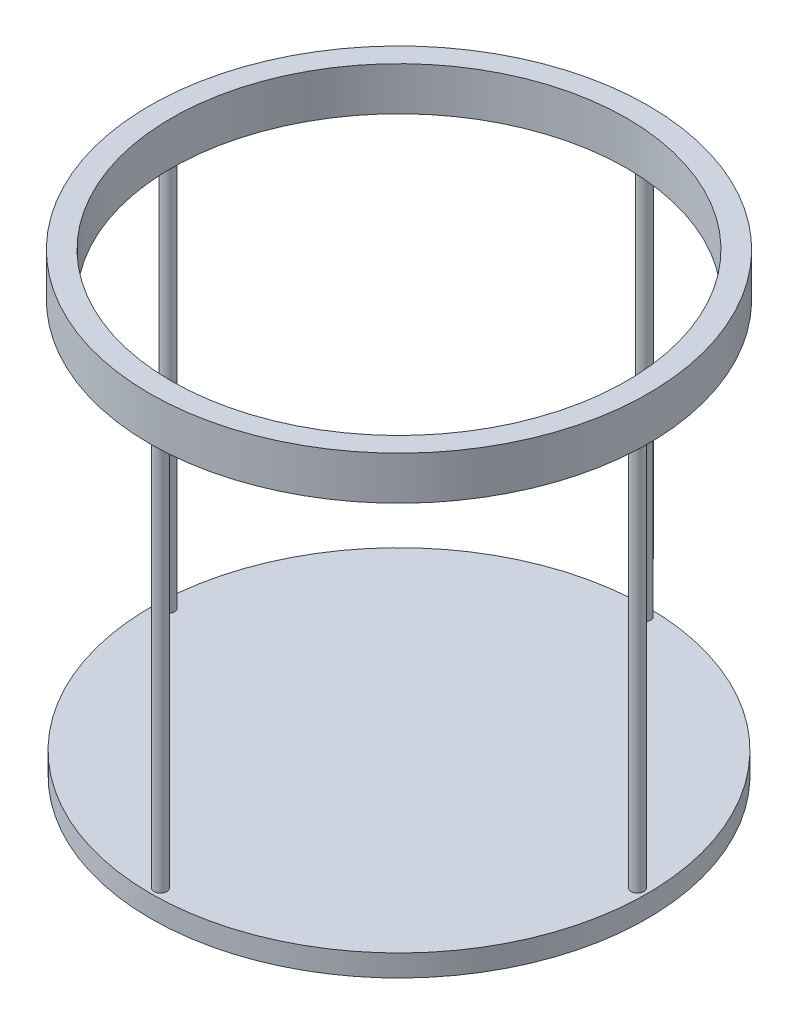
from build123d import *

# Parameters (mm, degrees)
SKETCH1_R           = 57.5
SKETCH1_R_2         = 52.5
BOSS_EXTRUDE1_DEPTH = 10
SKETCH2_R           = 1.45
BOSS_EXTRUDE2_DEPTH = 90
SKETCH4_R           = 57.227664134
BOSS_EXTRUDE3_DEPTH = 5


with BuildPart() as part:
    # Sketch1 → Boss-Extrude1 (new body)
    with BuildSketch(Plane(origin=(0, 0, 0), x_dir=(1, 0, 0), z_dir=(0, 1, 0))):
        Circle(SKETCH1_R)
        Circle(SKETCH1_R_2, mode=Mode.SUBTRACT)
    extrude(amount=BOSS_EXTRUDE1_DEPTH)

    # Sketch2 → Boss-Extrude2 (add)
    with BuildSketch(Plane.XZ):
        with Locations((0, 55)):
            Circle(SKETCH2_R)
        with Locations((1.578223765, -55)):
            Circle(SKETCH2_R)
        with Locations((55, 0)):
            Circle(SKETCH2_R)
        with Locations((-55, -1.760313132)):
            Circle(SKETCH2_R)
    extrude(amount=BOSS_EXTRUDE2_DEPTH)

    # Sketch4 → Boss-Extrude3 (add)
    with BuildSketch(Plane(origin=(0, -90, 0), x_dir=(-1, 0, 0), z_dir=(0, -1, 0))):
        Circle(SKETCH4_R)
    extrude(amount=BOSS_EXTRUDE3_DEPTH)


solid = part.part
